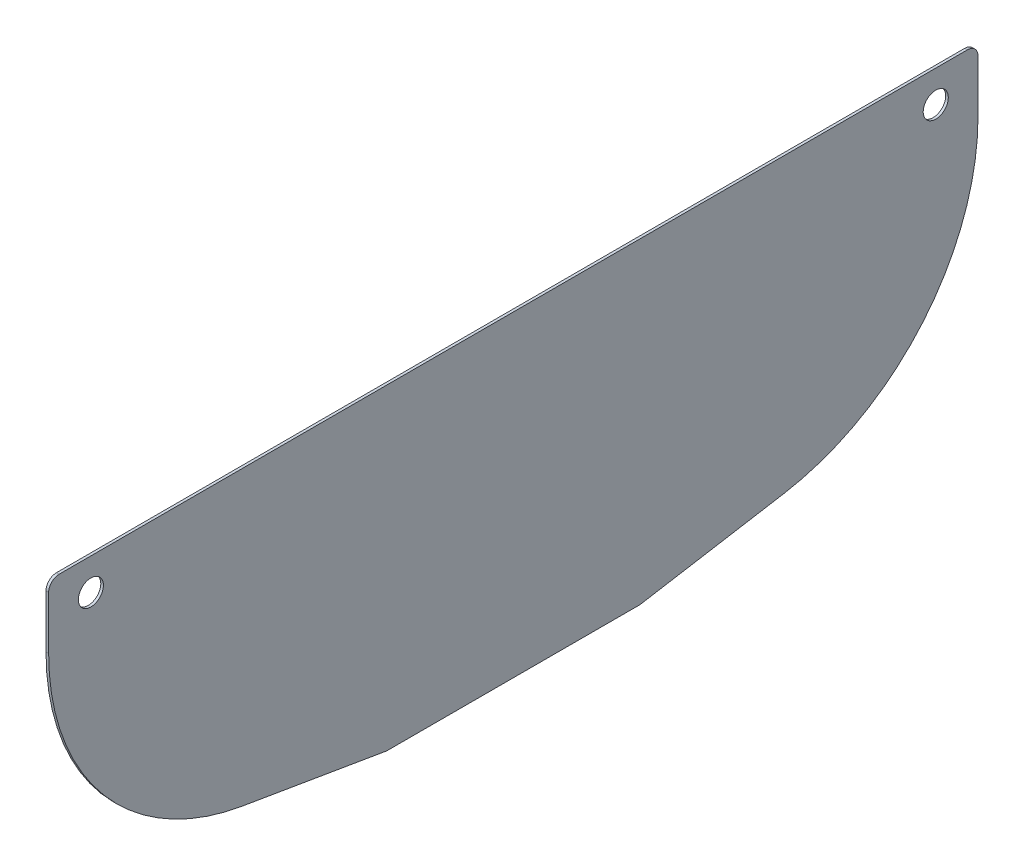
from build123d import *

# Parameters (mm, degrees)
SKETCH1_R           = 15.08125
BOSS_EXTRUDE1_DEPTH = 3.175
FILLET1_R           = 12.7


with BuildPart() as part:
    # Sketch1 → Boss-Extrude1 (new body)
    with BuildSketch(Plane(origin=(0, 0, 0), x_dir=(0, 0, -1), z_dir=(1, 0, 0))):
        with BuildLine():
            Line((-558.8, 609.6), (-558.8, 685.8))
            Line((-558.8, 685.8), (558.8, 685.8))
            Line((558.8, 685.8), (558.8, 609.6))
            ThreePointArc((558.8, 609.6), (492.779998657, 429.230002015), (325.91999876, 334.100000517))
            Line((325.91999876, 334.100000517), (152.4, 304.8))
            Line((152.4, 304.8), (-152.4, 304.8))
            Line((-152.4, 304.8), (-325.91999876, 334.100000517))
            ThreePointArc((-325.91999876, 334.100000517), (-492.779998657, 429.230002015), (-558.8, 609.6))
        make_face()
        with Locations((-508, 647.7)):
            Circle(SKETCH1_R, mode=Mode.SUBTRACT)
        with Locations((508, 647.7)):
            Circle(SKETCH1_R, mode=Mode.SUBTRACT)
    extrude(amount=BOSS_EXTRUDE1_DEPTH)

    # Fillet1
    fillet1_edges = [part.edges().sort_by_distance(p)[0] for p in [
        (1.5875, 304.8, -152.4),
        (1.5875, 304.8, 152.4),
        (1.5875, 685.8, 558.8),
        (1.5875, 685.8, -558.8),
    ]]
    fillet(fillet1_edges, radius=FILLET1_R)


solid = part.part
